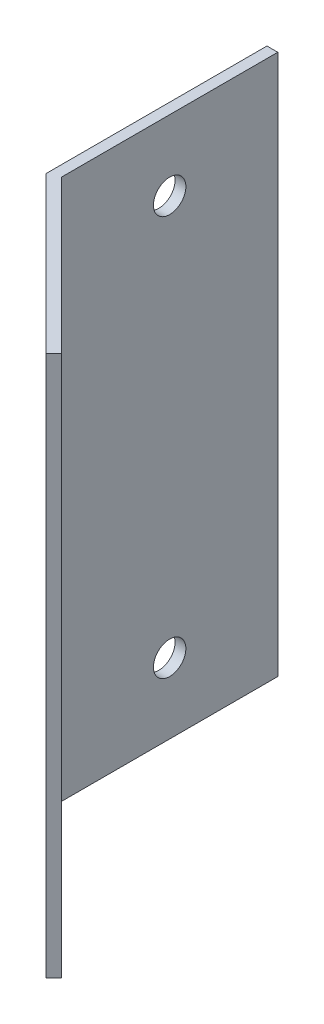
from build123d import *

# Parameters (mm, degrees)
EXTRUSION1_DEPTH = 50
EXTRUSION2_REACH = 3
ESQUISSE2_R      = 1.5
EXTRUSION3_REACH = 13.207
ESQUISSE3_R      = 1.5


with BuildPart() as part:
    # Esquisse1 → Extrusion1 (new body)
    with BuildSketch(Plane(origin=(0, 0, 0), x_dir=(1, 0, 0), z_dir=(0, 1, 0))):
        Polygon((0, 0), (0, 20.414213562), (1, 20.414213562), (1, 0.414213562), (15.142135624, -13.727922061), (14.435028843, -14.435028843), align=None)
    extrude(amount=EXTRUSION1_DEPTH)

    # Esquisse2 → Extrusion2 (cut, up to next)
    with BuildSketch(Plane(origin=(1, 0, 0), x_dir=(0, 0, -1), z_dir=(1, 0, 0)), mode=Mode.PRIVATE) as extrusion2_sk1:
        with Locations((10.414213562, 6.5)):
            Circle(ESQUISSE2_R)
    extrusion2_tool1 = extrude(extrusion2_sk1.sketch, amount=-EXTRUSION2_REACH, mode=Mode.PRIVATE) & part.part
    add(extrusion2_tool1.solids().sort_by_distance((1, 6.5, -10.414214))[0], mode=Mode.SUBTRACT)
    # Esquisse2 → Extrusion2 (cut, up to next)
    with BuildSketch(Plane(origin=(1, 0, 0), x_dir=(0, 0, -1), z_dir=(1, 0, 0)), mode=Mode.PRIVATE) as extrusion2_sk2:
        with Locations((10.414213562, 43.5)):
            Circle(ESQUISSE2_R)
    extrusion2_tool2 = extrude(extrusion2_sk2.sketch, amount=-EXTRUSION2_REACH, mode=Mode.PRIVATE) & part.part
    add(extrusion2_tool2.solids().sort_by_distance((1, 43.5, -10.414214))[0], mode=Mode.SUBTRACT)

    # Esquisse3 → Extrusion3 (cut, up to next)
    with BuildSketch(Plane(origin=(0.707106781, 0, -0.707106781), x_dir=(-0.707106781, 0, -0.707106781), z_dir=(0.707106781, 0, -0.707106781)), mode=Mode.PRIVATE) as extrusion3_sk1:
        with Locations((-10.414213562, 43.5)):
            Circle(ESQUISSE3_R)
    extrusion3_tool1 = extrude(extrusion3_sk1.sketch, amount=-EXTRUSION3_REACH, mode=Mode.PRIVATE) & part.part
    add(extrusion3_tool1.solids().sort_by_distance((8.071068, 43.5, 6.656854))[0], mode=Mode.SUBTRACT)
    # Esquisse3 → Extrusion3 (cut, up to next)
    with BuildSketch(Plane(origin=(0.707106781, 0, -0.707106781), x_dir=(-0.707106781, 0, -0.707106781), z_dir=(0.707106781, 0, -0.707106781)), mode=Mode.PRIVATE) as extrusion3_sk2:
        with Locations((-10.414213562, 6.5)):
            Circle(ESQUISSE3_R)
    extrusion3_tool2 = extrude(extrusion3_sk2.sketch, amount=-EXTRUSION3_REACH, mode=Mode.PRIVATE) & part.part
    add(extrusion3_tool2.solids().sort_by_distance((8.071068, 6.5, 6.656854))[0], mode=Mode.SUBTRACT)


solid = part.part
